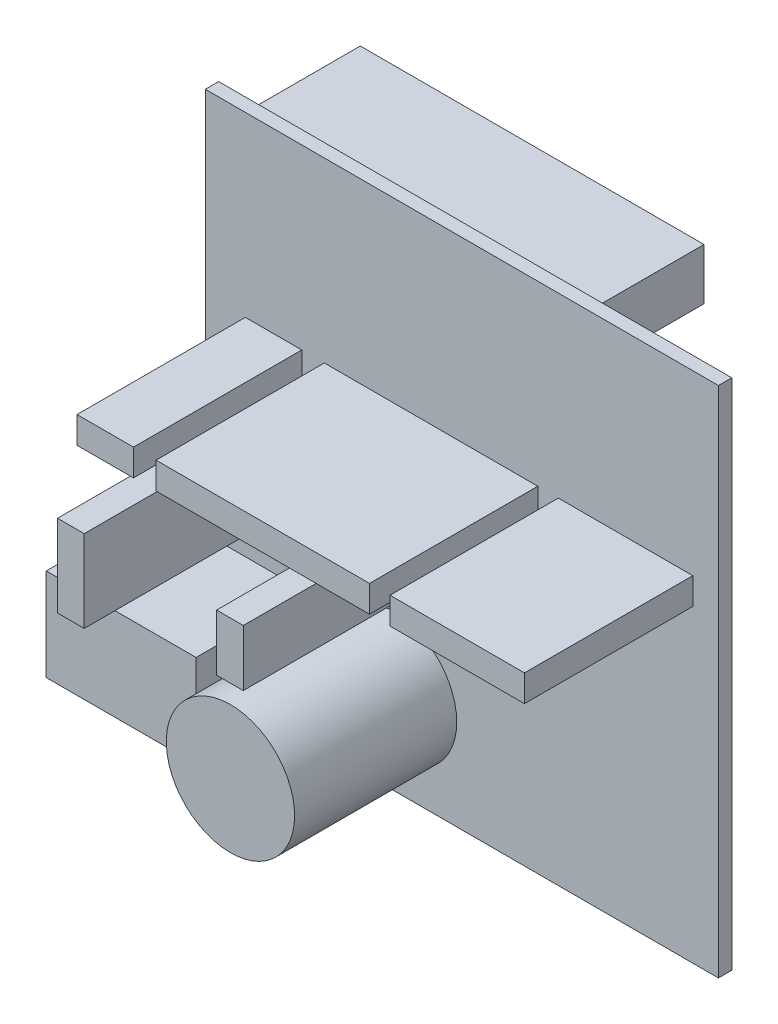
from build123d import *

# Parameters (mm, degrees)
CROQUIS1_W              = 50
CROQUIS1_H              = 50
SALIENTE_EXTRUIR1_DEPTH = 1.3
CROQUIS2_W              = 33.5
CROQUIS2_H              = 5
SALIENTE_EXTRUIR2_DEPTH = 11.1
CROQUIS3_W              = 14.6
CROQUIS3_H              = 9
SALIENTE_EXTRUIR3_DEPTH = 10.9
CROQUIS4_R              = 6.25
SALIENTE_EXTRUIR4_DEPTH = 15.8
CROQUIS5_W              = 13.1
CROQUIS5_H              = 2.6
CROQUIS5_W_2            = 20.8
CROQUIS5_W_3            = 5.5
CROQUIS5_W_4            = 2.6
CROQUIS5_H_2            = 8
CROQUIS5_H_3            = 5.5
SALIENTE_EXTRUIR5_DEPTH = 16.4


with BuildPart() as part:
    # Croquis1 → Saliente-Extruir1 (new body)
    with BuildSketch(Plane.XY):
        with Locations((25, -25)):
            Rectangle(CROQUIS1_W, CROQUIS1_H)
    extrude(amount=SALIENTE_EXTRUIR1_DEPTH)

    # Croquis2 → Saliente-Extruir2 (add)
    with BuildSketch(Plane(origin=(0, 0, 0), x_dir=(-1, 0, 0), z_dir=(0, 0, -1))):
        with Locations((-19.45, -3.7)):
            Rectangle(CROQUIS2_W, CROQUIS2_H)
    extrude(amount=SALIENTE_EXTRUIR2_DEPTH)

    # Croquis3 → Saliente-Extruir3 (add)
    with BuildSketch(Plane.XY.offset(1.3)):
        with Locations((2.7, -42)):
            Rectangle(CROQUIS3_W, CROQUIS3_H)
    extrude(amount=SALIENTE_EXTRUIR3_DEPTH)

    # Croquis4 → Saliente-Extruir4 (add)
    with BuildSketch(Plane.XY.offset(1.3)):
        with Locations((18.25, -41.15)):
            Circle(CROQUIS4_R)
    extrude(amount=SALIENTE_EXTRUIR4_DEPTH)

    # Croquis5 → Saliente-Extruir5 (add)
    with BuildSketch(Plane.XY.offset(1.3)):
        with Locations((40.95, -18.6)):
            Rectangle(CROQUIS5_W, CROQUIS5_H)
        with Locations((22, -18.6)):
            Rectangle(CROQUIS5_W_2, CROQUIS5_H)
        with Locations((6.65, -18.6)):
            Rectangle(CROQUIS5_W_3, CROQUIS5_H)
        with Locations((3.3, -31)):
            Rectangle(CROQUIS5_W_4, CROQUIS5_H_2)
        with Locations((18.8, -29.75)):
            Rectangle(CROQUIS5_W_4, CROQUIS5_H_3)
    extrude(amount=SALIENTE_EXTRUIR5_DEPTH)


solid = part.part
